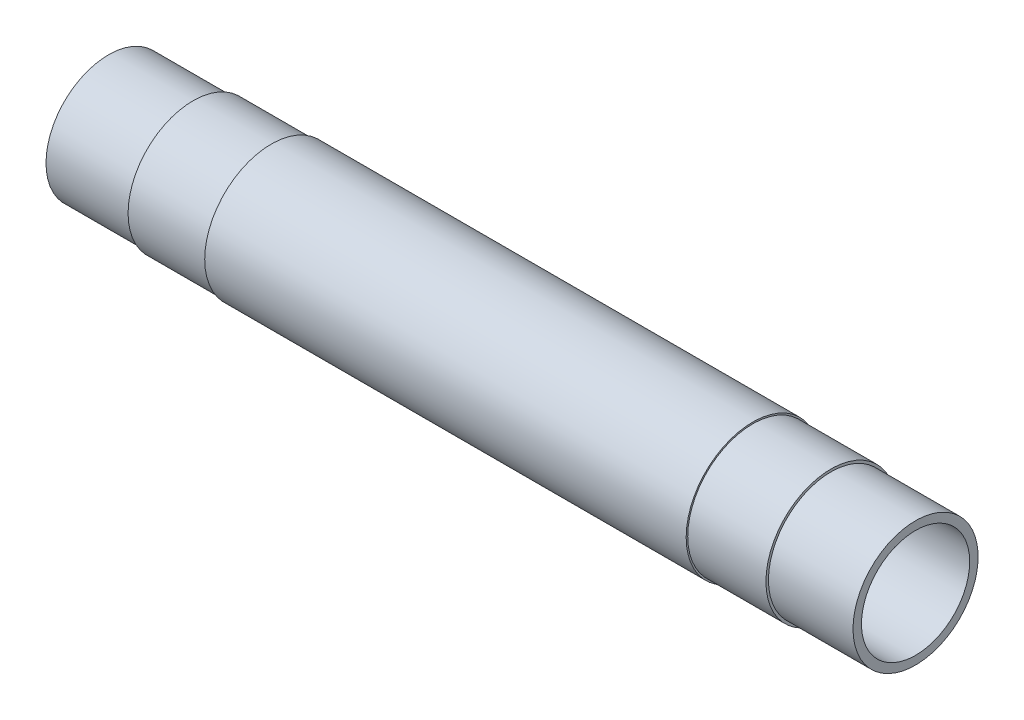
from build123d import *

# Parameters (mm, degrees)
SKETCH_1_R      = 10.65
SKETCH_1_R_2    = 8.65
EXTRUDE_1_DEPTH = 64.5


with BuildPart() as part:
    # Эскиз1 → Бобышка-Вытянуть1 (new body)
    with BuildSketch(Plane(origin=(0, 0, 0), x_dir=(0, 0, -1), z_dir=(1, 0, 0))):
        Circle(SKETCH_1_R)
        Circle(SKETCH_1_R_2, mode=Mode.SUBTRACT)
    extrude(amount=-EXTRUDE_1_DEPTH)

    # Эскиз2 → Вырез-Повернуть1 (revolve, cut)
    with BuildSketch(Plane.XY):
        Polygon((-38.480196097, 10.65), (-64.5, 10.65), (-64.5, 10), (-50.980196097, 10), (-50.980196097, 10.4), (-38.480196097, 10.4), align=None)
    revolve(axis=Axis((-1000, 0, 0), (1, 0, 0)), mode=Mode.SUBTRACT)

    # Зеркальное отражение1: part across plane


with BuildPart() as part_1:
    add(part.part)
    add(part.part.mirror(Plane(origin=(0, 0, 0), x_dir=(0, 0, 1), z_dir=(1, 0, 0))))


solid = part_1.part
